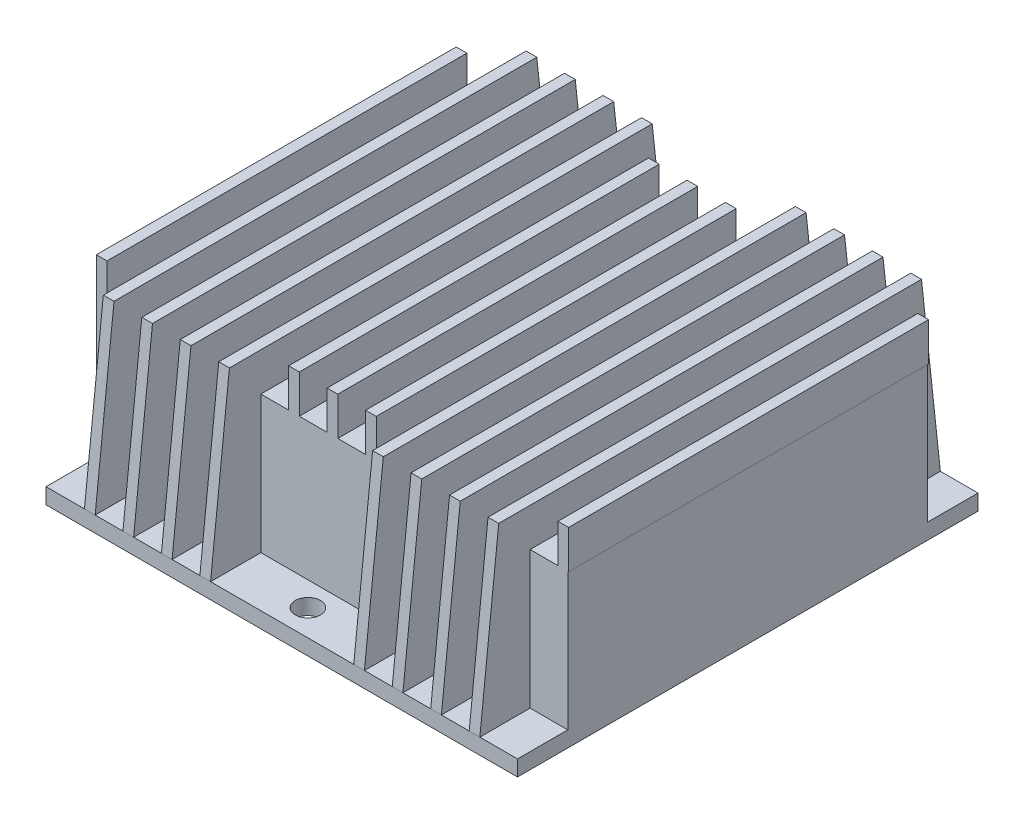
from build123d import *

# Parameters (mm, degrees)
SKETCH1_W                      = 75
SKETCH1_H                      = 73.25
BOSS_EXTRUDE1_DEPTH            = 2.5
SKETCH2_W                      = 75
SKETCH2_H                      = 57.25
BOSS_EXTRUDE2_DEPTH            = 21.85
BOSS_EXTRUDE3_DEPTH            = 1.7
LPATTERN1_COUNT                = 13
LPATTERN1_PITCH                = 6.119230769
CUT_EXTRUDE1_REACH             = 26.35
SKETCH4_W                      = 1.7
SKETCH4_H                      = 8
CUT_EXTRUDE1_DIRECTION_2_REACH = 8.1
SKETCH5_R                      = 2
CUT_EXTRUDE2_DEPTH             = 3.5
SKETCH6_W                      = 31.6
SKETCH6_H                      = 16.5
BOSS_EXTRUDE4_DEPTH            = 2.5


with BuildPart() as part:
    # Sketch1 → Boss-Extrude1 (new body)
    with BuildSketch(Plane(origin=(0, 0, 0), x_dir=(1, 0, 0), z_dir=(0, 1, 0))):
        Rectangle(SKETCH1_W, SKETCH1_H)
    extrude(amount=BOSS_EXTRUDE1_DEPTH)

    # Sketch2 → Boss-Extrude2 (add)
    with BuildSketch(Plane(origin=(0, 2.5, 0), x_dir=(1, 0, 0), z_dir=(0, 1, 0))):
        Rectangle(SKETCH2_W, SKETCH2_H)
    extrude(amount=BOSS_EXTRUDE2_DEPTH)

    # Sketch3 → Boss-Extrude3 (add)
    with BuildSketch(Plane.ZY.offset(37.5)):
        Polygon((-33.625, 30.45), (33.625, 30.45), (36.625, 2.5), (28.625, 2.5), (28.625, 24.35), (-28.625, 24.35), (-28.625, 2.5), (-36.625, 2.5), align=None)
    boss_extrude3 = extrude(amount=-BOSS_EXTRUDE3_DEPTH)

    # LPattern1: Boss-Extrude3 ×13
    with Locations(*[(i * LPATTERN1_PITCH, 0, 0) for i in range(1, LPATTERN1_COUNT)]):
        add(boss_extrude3)

    # Cut-Extrude1: up to this face of the body (flat: up to its plane)
    cut_extrude1_end = Plane(part.part.faces().sort_by_distance((33.721153846, 2.5, -32.625))[0])
    # Sketch4 → Cut-Extrude1 (cut, up to the picked face)
    with BuildSketch(Plane(origin=(0, 24.35, 0), x_dir=(1, 0, 0), z_dir=(0, 1, 0)), mode=Mode.PRIVATE) as cut_extrude1_sk1:
        with Locations((-36.65, -32.625)):
            Rectangle(SKETCH4_W, SKETCH4_H)
    cut_extrude1_tool1 = split(extrude(cut_extrude1_sk1.sketch, amount=-CUT_EXTRUDE1_REACH, mode=Mode.PRIVATE), bisect_by=cut_extrude1_end, keep=Keep.BOTH, mode=Mode.PRIVATE)
    add(cut_extrude1_tool1.solids().sort_by_distance((-36.65, 24.35, 32.625))[0], mode=Mode.SUBTRACT)
    # Sketch4 → Cut-Extrude1 (cut, up to the picked face)
    with BuildSketch(Plane(origin=(0, 24.35, 0), x_dir=(1, 0, 0), z_dir=(0, 1, 0)), mode=Mode.PRIVATE) as cut_extrude1_sk2:
        with Locations((-6.053846154, -32.625)):
            Rectangle(SKETCH4_W, SKETCH4_H)
    cut_extrude1_tool2 = split(extrude(cut_extrude1_sk2.sketch, amount=-CUT_EXTRUDE1_REACH, mode=Mode.PRIVATE), bisect_by=cut_extrude1_end, keep=Keep.BOTH, mode=Mode.PRIVATE)
    add(cut_extrude1_tool2.solids().sort_by_distance((-6.053846, 24.35, 32.625))[0], mode=Mode.SUBTRACT)
    # Sketch4 → Cut-Extrude1 (cut, up to the picked face)
    with BuildSketch(Plane(origin=(0, 24.35, 0), x_dir=(1, 0, 0), z_dir=(0, 1, 0)), mode=Mode.PRIVATE) as cut_extrude1_sk3:
        with Locations((0.065384615, -32.625)):
            Rectangle(SKETCH4_W, SKETCH4_H)
    cut_extrude1_tool3 = split(extrude(cut_extrude1_sk3.sketch, amount=-CUT_EXTRUDE1_REACH, mode=Mode.PRIVATE), bisect_by=cut_extrude1_end, keep=Keep.BOTH, mode=Mode.PRIVATE)
    add(cut_extrude1_tool3.solids().sort_by_distance((0.065385, 24.35, 32.625))[0], mode=Mode.SUBTRACT)
    # Sketch4 → Cut-Extrude1 (cut, up to the picked face)
    with BuildSketch(Plane(origin=(0, 24.35, 0), x_dir=(1, 0, 0), z_dir=(0, 1, 0)), mode=Mode.PRIVATE) as cut_extrude1_sk4:
        with Locations((6.184615385, -32.625)):
            Rectangle(SKETCH4_W, SKETCH4_H)
    cut_extrude1_tool4 = split(extrude(cut_extrude1_sk4.sketch, amount=-CUT_EXTRUDE1_REACH, mode=Mode.PRIVATE), bisect_by=cut_extrude1_end, keep=Keep.BOTH, mode=Mode.PRIVATE)
    add(cut_extrude1_tool4.solids().sort_by_distance((6.184615, 24.35, 32.625))[0], mode=Mode.SUBTRACT)
    # Sketch4 → Cut-Extrude1 (cut, up to the picked face)
    with BuildSketch(Plane(origin=(0, 24.35, 0), x_dir=(1, 0, 0), z_dir=(0, 1, 0)), mode=Mode.PRIVATE) as cut_extrude1_sk5:
        with Locations((36.780769231, -32.625)):
            Rectangle(SKETCH4_W, SKETCH4_H)
    cut_extrude1_tool5 = split(extrude(cut_extrude1_sk5.sketch, amount=-CUT_EXTRUDE1_REACH, mode=Mode.PRIVATE), bisect_by=cut_extrude1_end, keep=Keep.BOTH, mode=Mode.PRIVATE)
    add(cut_extrude1_tool5.solids().sort_by_distance((36.780769, 24.35, 32.625))[0], mode=Mode.SUBTRACT)
    # Sketch4 → Cut-Extrude1 (cut, up to the picked face)
    with BuildSketch(Plane(origin=(0, 24.35, 0), x_dir=(1, 0, 0), z_dir=(0, 1, 0)), mode=Mode.PRIVATE) as cut_extrude1_sk6:
        with Locations((-36.65, 32.625)):
            Rectangle(SKETCH4_W, SKETCH4_H)
    cut_extrude1_tool6 = split(extrude(cut_extrude1_sk6.sketch, amount=-CUT_EXTRUDE1_REACH, mode=Mode.PRIVATE), bisect_by=cut_extrude1_end, keep=Keep.BOTH, mode=Mode.PRIVATE)
    add(cut_extrude1_tool6.solids().sort_by_distance((-36.65, 24.35, -32.625))[0], mode=Mode.SUBTRACT)
    # Sketch4 → Cut-Extrude1 (cut, up to the picked face)
    with BuildSketch(Plane(origin=(0, 24.35, 0), x_dir=(1, 0, 0), z_dir=(0, 1, 0)), mode=Mode.PRIVATE) as cut_extrude1_sk7:
        with Locations((-6.053846154, 32.625)):
            Rectangle(SKETCH4_W, SKETCH4_H)
    cut_extrude1_tool7 = split(extrude(cut_extrude1_sk7.sketch, amount=-CUT_EXTRUDE1_REACH, mode=Mode.PRIVATE), bisect_by=cut_extrude1_end, keep=Keep.BOTH, mode=Mode.PRIVATE)
    add(cut_extrude1_tool7.solids().sort_by_distance((-6.053846, 24.35, -32.625))[0], mode=Mode.SUBTRACT)
    # Sketch4 → Cut-Extrude1 (cut, up to the picked face)
    with BuildSketch(Plane(origin=(0, 24.35, 0), x_dir=(1, 0, 0), z_dir=(0, 1, 0)), mode=Mode.PRIVATE) as cut_extrude1_sk8:
        with Locations((6.184615385, 32.625)):
            Rectangle(SKETCH4_W, SKETCH4_H)
    cut_extrude1_tool8 = split(extrude(cut_extrude1_sk8.sketch, amount=-CUT_EXTRUDE1_REACH, mode=Mode.PRIVATE), bisect_by=cut_extrude1_end, keep=Keep.BOTH, mode=Mode.PRIVATE)
    add(cut_extrude1_tool8.solids().sort_by_distance((6.184615, 24.35, -32.625))[0], mode=Mode.SUBTRACT)
    # Sketch4 → Cut-Extrude1 (cut, up to the picked face)
    with BuildSketch(Plane(origin=(0, 24.35, 0), x_dir=(1, 0, 0), z_dir=(0, 1, 0)), mode=Mode.PRIVATE) as cut_extrude1_sk9:
        with Locations((36.780769231, 32.625)):
            Rectangle(SKETCH4_W, SKETCH4_H)
    cut_extrude1_tool9 = split(extrude(cut_extrude1_sk9.sketch, amount=-CUT_EXTRUDE1_REACH, mode=Mode.PRIVATE), bisect_by=cut_extrude1_end, keep=Keep.BOTH, mode=Mode.PRIVATE)
    add(cut_extrude1_tool9.solids().sort_by_distance((36.780769, 24.35, -32.625))[0], mode=Mode.SUBTRACT)
    # Sketch4 → Cut-Extrude1 (cut, up to the picked face)
    with BuildSketch(Plane(origin=(0, 24.35, 0), x_dir=(1, 0, 0), z_dir=(0, 1, 0)), mode=Mode.PRIVATE) as cut_extrude1_sk10:
        with Locations((0.065384615, 32.625)):
            Rectangle(SKETCH4_W, SKETCH4_H)
    cut_extrude1_tool10 = split(extrude(cut_extrude1_sk10.sketch, amount=-CUT_EXTRUDE1_REACH, mode=Mode.PRIVATE), bisect_by=cut_extrude1_end, keep=Keep.BOTH, mode=Mode.PRIVATE)
    add(cut_extrude1_tool10.solids().sort_by_distance((0.065385, 24.35, -32.625))[0], mode=Mode.SUBTRACT)

    # Cut-Extrude1 direction 2: up to this face of the body (flat: up to its plane)
    cut_extrude1_direction_2_end = Plane(part.part.faces().sort_by_distance((36.780769231, 30.45, 0))[0])
    # Sketch4 → Cut-Extrude1 direction 2 (cut, up to the picked face)
    with BuildSketch(Plane(origin=(0, 24.35, 0), x_dir=(1, 0, 0), z_dir=(0, 1, 0)), mode=Mode.PRIVATE) as cut_extrude1_direction_2_sk1:
        with Locations((-36.65, -32.625)):
            Rectangle(SKETCH4_W, SKETCH4_H)
    cut_extrude1_direction_2_tool1 = split(extrude(cut_extrude1_direction_2_sk1.sketch, amount=CUT_EXTRUDE1_DIRECTION_2_REACH, mode=Mode.PRIVATE), bisect_by=cut_extrude1_direction_2_end, keep=Keep.BOTH, mode=Mode.PRIVATE)
    add(cut_extrude1_direction_2_tool1.solids().sort_by_distance((-36.65, 24.35, 32.625))[0], mode=Mode.SUBTRACT)
    # Sketch4 → Cut-Extrude1 direction 2 (cut, up to the picked face)
    with BuildSketch(Plane(origin=(0, 24.35, 0), x_dir=(1, 0, 0), z_dir=(0, 1, 0)), mode=Mode.PRIVATE) as cut_extrude1_direction_2_sk2:
        with Locations((-6.053846154, -32.625)):
            Rectangle(SKETCH4_W, SKETCH4_H)
    cut_extrude1_direction_2_tool2 = split(extrude(cut_extrude1_direction_2_sk2.sketch, amount=CUT_EXTRUDE1_DIRECTION_2_REACH, mode=Mode.PRIVATE), bisect_by=cut_extrude1_direction_2_end, keep=Keep.BOTH, mode=Mode.PRIVATE)
    add(cut_extrude1_direction_2_tool2.solids().sort_by_distance((-6.053846, 24.35, 32.625))[0], mode=Mode.SUBTRACT)
    # Sketch4 → Cut-Extrude1 direction 2 (cut, up to the picked face)
    with BuildSketch(Plane(origin=(0, 24.35, 0), x_dir=(1, 0, 0), z_dir=(0, 1, 0)), mode=Mode.PRIVATE) as cut_extrude1_direction_2_sk3:
        with Locations((0.065384615, -32.625)):
            Rectangle(SKETCH4_W, SKETCH4_H)
    cut_extrude1_direction_2_tool3 = split(extrude(cut_extrude1_direction_2_sk3.sketch, amount=CUT_EXTRUDE1_DIRECTION_2_REACH, mode=Mode.PRIVATE), bisect_by=cut_extrude1_direction_2_end, keep=Keep.BOTH, mode=Mode.PRIVATE)
    add(cut_extrude1_direction_2_tool3.solids().sort_by_distance((0.065385, 24.35, 32.625))[0], mode=Mode.SUBTRACT)
    # Sketch4 → Cut-Extrude1 direction 2 (cut, up to the picked face)
    with BuildSketch(Plane(origin=(0, 24.35, 0), x_dir=(1, 0, 0), z_dir=(0, 1, 0)), mode=Mode.PRIVATE) as cut_extrude1_direction_2_sk4:
        with Locations((6.184615385, -32.625)):
            Rectangle(SKETCH4_W, SKETCH4_H)
    cut_extrude1_direction_2_tool4 = split(extrude(cut_extrude1_direction_2_sk4.sketch, amount=CUT_EXTRUDE1_DIRECTION_2_REACH, mode=Mode.PRIVATE), bisect_by=cut_extrude1_direction_2_end, keep=Keep.BOTH, mode=Mode.PRIVATE)
    add(cut_extrude1_direction_2_tool4.solids().sort_by_distance((6.184615, 24.35, 32.625))[0], mode=Mode.SUBTRACT)
    # Sketch4 → Cut-Extrude1 direction 2 (cut, up to the picked face)
    with BuildSketch(Plane(origin=(0, 24.35, 0), x_dir=(1, 0, 0), z_dir=(0, 1, 0)), mode=Mode.PRIVATE) as cut_extrude1_direction_2_sk5:
        with Locations((36.780769231, -32.625)):
            Rectangle(SKETCH4_W, SKETCH4_H)
    cut_extrude1_direction_2_tool5 = split(extrude(cut_extrude1_direction_2_sk5.sketch, amount=CUT_EXTRUDE1_DIRECTION_2_REACH, mode=Mode.PRIVATE), bisect_by=cut_extrude1_direction_2_end, keep=Keep.BOTH, mode=Mode.PRIVATE)
    add(cut_extrude1_direction_2_tool5.solids().sort_by_distance((36.780769, 24.35, 32.625))[0], mode=Mode.SUBTRACT)
    # Sketch4 → Cut-Extrude1 direction 2 (cut, up to the picked face)
    with BuildSketch(Plane(origin=(0, 24.35, 0), x_dir=(1, 0, 0), z_dir=(0, 1, 0)), mode=Mode.PRIVATE) as cut_extrude1_direction_2_sk6:
        with Locations((-36.65, 32.625)):
            Rectangle(SKETCH4_W, SKETCH4_H)
    cut_extrude1_direction_2_tool6 = split(extrude(cut_extrude1_direction_2_sk6.sketch, amount=CUT_EXTRUDE1_DIRECTION_2_REACH, mode=Mode.PRIVATE), bisect_by=cut_extrude1_direction_2_end, keep=Keep.BOTH, mode=Mode.PRIVATE)
    add(cut_extrude1_direction_2_tool6.solids().sort_by_distance((-36.65, 24.35, -32.625))[0], mode=Mode.SUBTRACT)
    # Sketch4 → Cut-Extrude1 direction 2 (cut, up to the picked face)
    with BuildSketch(Plane(origin=(0, 24.35, 0), x_dir=(1, 0, 0), z_dir=(0, 1, 0)), mode=Mode.PRIVATE) as cut_extrude1_direction_2_sk7:
        with Locations((-6.053846154, 32.625)):
            Rectangle(SKETCH4_W, SKETCH4_H)
    cut_extrude1_direction_2_tool7 = split(extrude(cut_extrude1_direction_2_sk7.sketch, amount=CUT_EXTRUDE1_DIRECTION_2_REACH, mode=Mode.PRIVATE), bisect_by=cut_extrude1_direction_2_end, keep=Keep.BOTH, mode=Mode.PRIVATE)
    add(cut_extrude1_direction_2_tool7.solids().sort_by_distance((-6.053846, 24.35, -32.625))[0], mode=Mode.SUBTRACT)
    # Sketch4 → Cut-Extrude1 direction 2 (cut, up to the picked face)
    with BuildSketch(Plane(origin=(0, 24.35, 0), x_dir=(1, 0, 0), z_dir=(0, 1, 0)), mode=Mode.PRIVATE) as cut_extrude1_direction_2_sk8:
        with Locations((6.184615385, 32.625)):
            Rectangle(SKETCH4_W, SKETCH4_H)
    cut_extrude1_direction_2_tool8 = split(extrude(cut_extrude1_direction_2_sk8.sketch, amount=CUT_EXTRUDE1_DIRECTION_2_REACH, mode=Mode.PRIVATE), bisect_by=cut_extrude1_direction_2_end, keep=Keep.BOTH, mode=Mode.PRIVATE)
    add(cut_extrude1_direction_2_tool8.solids().sort_by_distance((6.184615, 24.35, -32.625))[0], mode=Mode.SUBTRACT)
    # Sketch4 → Cut-Extrude1 direction 2 (cut, up to the picked face)
    with BuildSketch(Plane(origin=(0, 24.35, 0), x_dir=(1, 0, 0), z_dir=(0, 1, 0)), mode=Mode.PRIVATE) as cut_extrude1_direction_2_sk9:
        with Locations((36.780769231, 32.625)):
            Rectangle(SKETCH4_W, SKETCH4_H)
    cut_extrude1_direction_2_tool9 = split(extrude(cut_extrude1_direction_2_sk9.sketch, amount=CUT_EXTRUDE1_DIRECTION_2_REACH, mode=Mode.PRIVATE), bisect_by=cut_extrude1_direction_2_end, keep=Keep.BOTH, mode=Mode.PRIVATE)
    add(cut_extrude1_direction_2_tool9.solids().sort_by_distance((36.780769, 24.35, -32.625))[0], mode=Mode.SUBTRACT)
    # Sketch4 → Cut-Extrude1 direction 2 (cut, up to the picked face)
    with BuildSketch(Plane(origin=(0, 24.35, 0), x_dir=(1, 0, 0), z_dir=(0, 1, 0)), mode=Mode.PRIVATE) as cut_extrude1_direction_2_sk10:
        with Locations((0.065384615, 32.625)):
            Rectangle(SKETCH4_W, SKETCH4_H)
    cut_extrude1_direction_2_tool10 = split(extrude(cut_extrude1_direction_2_sk10.sketch, amount=CUT_EXTRUDE1_DIRECTION_2_REACH, mode=Mode.PRIVATE), bisect_by=cut_extrude1_direction_2_end, keep=Keep.BOTH, mode=Mode.PRIVATE)
    add(cut_extrude1_direction_2_tool10.solids().sort_by_distance((0.065385, 24.35, -32.625))[0], mode=Mode.SUBTRACT)

    # Sketch5 → Cut-Extrude2 (cut, through all)
    with BuildSketch(Plane(origin=(0, 2.5, 0), x_dir=(1, 0, 0), z_dir=(0, 1, 0))):
        with Locations((0, 32.475)):
            Circle(SKETCH5_R)
        with Locations((0, -32.475)):
            Circle(SKETCH5_R)
    extrude(amount=-CUT_EXTRUDE2_DEPTH, mode=Mode.SUBTRACT)

    # Sketch6 → Boss-Extrude4 (add)
    with BuildSketch(Plane.ZY.offset(37.5)):
        with Locations((0, 8.25)):
            Rectangle(SKETCH6_W, SKETCH6_H)
    extrude(amount=BOSS_EXTRUDE4_DEPTH)


solid = part.part
